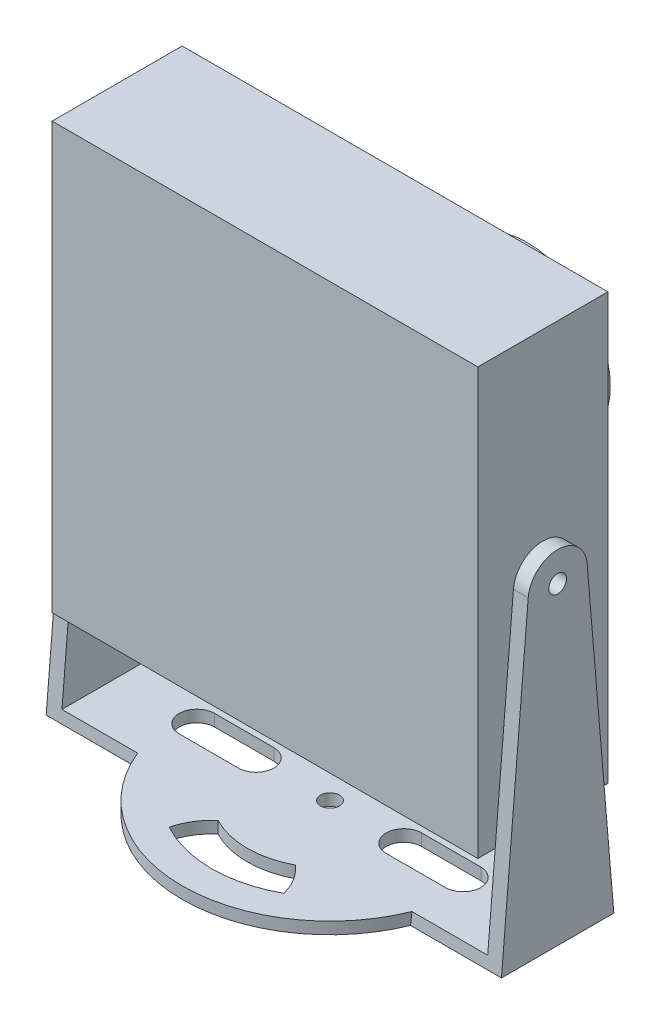
from build123d import *

# Parameters (mm, degrees)
SKETCH_1_W             = 36
SKETCH_1_H             = 36
EXTRUDE_1_DEPTH        = 11
SKETCH_2_W             = 32
SKETCH_2_H             = 32
SKETCH_2_R             = 1.25
EXTRUDE_2_DEPTH        = 2
EXTRUDE_START          = -11
SKETCH_3_R             = 7
EXTRUDE_3_DEPTH        = 22.2
SKETCH_4_W             = 1
SKETCH_4_H             = 2
SKETCH_5_R             = 5
CUT_EXTRUDE_1_DEPTH    = 0.9
EXTRUDE_START_2        = 19.25
SKETCH_6_R             = 0.75
EXTRUDE_4_DEPTH        = 1.25
EXTRUDE_5_DEPTH        = 37.25
SKETCH_9_R             = 12.5
SKETCH_9_R_2           = 1
EXTRUDE_6_DEPTH        = 1
CUT_EXTRUDE_2_DEPTH    = 2
SKETCH_10_R            = 0.75
EXTRUDE_7_DEPTH        = 1.25
HOLE_WIZARD_M2_1_D     = 1.6
HOLE_WIZARD_M2_1_DEPTH = 2
HOLE_WIZARD_M2_1_TIP   = 0.480688495


with BuildPart() as part:
    # 草图1 → 凸台-拉伸1 (new body)
    with BuildSketch(Plane.XY):
        Rectangle(SKETCH_1_W, SKETCH_1_H)
    extrude(amount=EXTRUDE_1_DEPTH)

    # 草图2 → 凸台-拉伸2 (add)
    with BuildSketch(Plane(origin=(0, 0, 0), x_dir=(-1, 0, 0), z_dir=(0, 0, -1))):
        Rectangle(SKETCH_2_W, SKETCH_2_H)
        with Locations((-14, 14)):
            Circle(SKETCH_2_R, mode=Mode.SUBTRACT)
        with Locations(Location((14, -14, 0), (0, 0, 180))):
            Circle(SKETCH_2_R, mode=Mode.SUBTRACT)
        with Locations(Location((14, 14, 0), (0, 0, 180))):
            Circle(SKETCH_2_R, mode=Mode.SUBTRACT)
        with Locations((-14, -14)):
            Circle(SKETCH_2_R, mode=Mode.SUBTRACT)
    extrude(amount=EXTRUDE_2_DEPTH)

    # 草图3 → 凸台-拉伸3 (add)
    with BuildSketch(Plane(origin=(0, 0, 0), x_dir=(-1, 0, 0), z_dir=(0, 0, -1)).offset(EXTRUDE_START)):
        with Locations(Location((0, 0, 0), (0, 0, 180))):
            Circle(SKETCH_3_R)
    extrude(amount=EXTRUDE_3_DEPTH)

    # 草图4 → 切除-旋转1 (revolve, cut)
    with BuildSketch(Plane(origin=(0, 0, 0), x_dir=(0, 0, -1), z_dir=(1, 0, 0)), mode=Mode.PRIVATE) as cut_revolve_1_sk:
        with Locations((9, 7)):
            Rectangle(SKETCH_4_W, SKETCH_4_H)
    revolve(cut_revolve_1_sk.sketch.rotate(Axis((0, 0, 0), (0, 0, -1)), 90), axis=Axis((0, 0, 0), (0, 0, -1)), mode=Mode.SUBTRACT)

    # 草图5 → 切除-拉伸1 (cut)
    with BuildSketch(Plane(origin=(0, 0, -11.2), x_dir=(-1, 0, 0), z_dir=(0, 0, -1))):
        Circle(SKETCH_5_R)
    extrude(amount=-CUT_EXTRUDE_1_DEPTH, mode=Mode.SUBTRACT)

    # 草图6 → 凸台-拉伸4 (add)
    with BuildSketch(Plane(origin=(0, 0, 0), x_dir=(0, 0, -1), z_dir=(1, 0, 0)).offset(EXTRUDE_START_2)):
        with BuildLine():
            Line((-0.75, -26.5), (-3.008892206, 0.210670265))
            ThreePointArc((-3.008892206, 0.210670265), (-5.5, 2.5), (-7.991107794, 0.210670265))
            Line((-7.991107794, 0.210670265), (-10.25, -26.5))
            Line((-10.25, -26.5), (-0.75, -26.5))
        make_face()
        with Locations((-5.5, 0)):
            Circle(SKETCH_6_R, mode=Mode.SUBTRACT)
    extrude(amount=-EXTRUDE_4_DEPTH)

    # 草图7 → 凸台-拉伸5 (add)
    with BuildSketch(Plane.ZY.offset(-18)):
        Polygon((0.834568908, -25.5), (10.165431092, -25.5), (10.25, -26.5), (0.75, -26.5), align=None)
    extrude(amount=EXTRUDE_5_DEPTH)

    # 草图9 → 凸台-拉伸6 (add)
    with BuildSketch(Plane.XZ.offset(26.5)):
        with Locations((0, 5.5)):
            Circle(SKETCH_9_R)
        with Locations((0, 5.5)):
            Circle(SKETCH_9_R_2, mode=Mode.SUBTRACT)
        with BuildLine():
            ThreePointArc((4.850909325, 14.244637141), (0, 15.5), (-4.850909325, 14.244637141))
            ThreePointArc((-4.850909325, 14.244637141), (-4.258969051, 12.844732491), (-3.274022071, 11.687146312))
            ThreePointArc((-3.274022071, 11.687146312), (0, 12.5), (3.274022071, 11.687146312))
            ThreePointArc((3.274022071, 11.687146312), (4.258969051, 12.844732491), (4.850909325, 14.244637141))
        make_face(mode=Mode.SUBTRACT)
        with BuildLine():
            ThreePointArc((-4.850909325, -3.244637141), (-4.258969051, -1.844732491), (-3.274022071, -0.687146312))
            ThreePointArc((-3.274022071, -0.687146312), (0, -1.5), (3.274022071, -0.687146312))
            ThreePointArc((3.274022071, -0.687146312), (4.258969051, -1.844732491), (4.850909325, -3.244637141))
            ThreePointArc((4.850909325, -3.244637141), (0, -4.5), (-4.850909325, -3.244637141))
        make_face(mode=Mode.SUBTRACT)
    extrude(amount=-EXTRUDE_6_DEPTH)

    # 草图8 → 切除-拉伸2 (cut)
    with BuildSketch(Plane.XZ.offset(26.5)):
        with BuildLine():
            Line((6.25, 7), (11.25, 7))
            ThreePointArc((11.25, 7), (12.75, 5.5), (11.25, 4))
            Line((11.25, 4), (6.25, 4))
            ThreePointArc((6.25, 4), (4.75, 5.5), (6.25, 7))
        make_face()
    cut_extrude_2 = extrude(amount=-CUT_EXTRUDE_2_DEPTH, mode=Mode.SUBTRACT)

    # 草图10 → 凸台-拉伸7 (add)
    with BuildSketch(Plane.ZY.offset(18)):
        with BuildLine():
            Line((3.008892206, 0.210670265), (0.75, -26.5))
            Line((0.75, -26.5), (10.25, -26.5))
            Line((10.25, -26.5), (7.991107794, 0.210670265))
            ThreePointArc((7.991107794, 0.210670265), (5.5, 2.5), (3.008892206, 0.210670265))
        make_face()
        with Locations(Location((5.5, 0, 0), (0, 0, 180))):
            Circle(SKETCH_10_R, mode=Mode.SUBTRACT)
    extrude(amount=EXTRUDE_7_DEPTH)

    # 镜向3: 切除-拉伸2 across plane
    add(cut_extrude_2.mirror(Plane(origin=(0, 0, 0), x_dir=(0, 0, 1), z_dir=(1, 0, 0))), mode=Mode.SUBTRACT)

    # M2 螺纹孔的螺纹孔钻头1
    with Locations(Plane(origin=(0, -26.5, 0), x_dir=(-1, 0, 0), z_dir=(0, -1, 0))):
        with Locations((0, -5.5)):
            Hole(HOLE_WIZARD_M2_1_D / 2, depth=HOLE_WIZARD_M2_1_DEPTH)
            with Locations((0, 0, -(HOLE_WIZARD_M2_1_DEPTH + HOLE_WIZARD_M2_1_TIP / 2))):  # 118° drill point
                Cone(0, HOLE_WIZARD_M2_1_D / 2, HOLE_WIZARD_M2_1_TIP, mode=Mode.SUBTRACT)


solid = part.part
